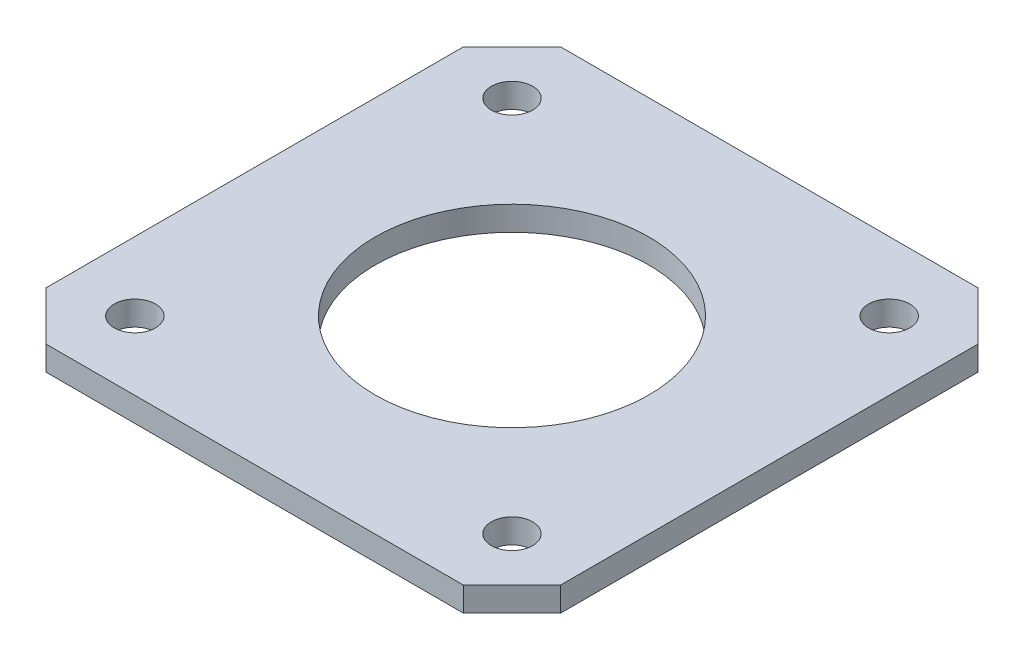
from build123d import *

# Parameters (mm, degrees)
SKETCH1_W            = 42.3
SKETCH1_H            = 42.3
BOSS_EXTRUDE1_DEPTH  = 2
SKETCH2_R            = 11.25
CUT_EXTRUDE1_DEPTH   = 3
M3_CLEARANCE_HOLE1_D = 3.4
CHAMFER1_SIZE        = 4


with BuildPart() as part:
    # Sketch1 → Boss-Extrude1 (new body)
    with BuildSketch(Plane(origin=(0, 0, 0), x_dir=(1, 0, 0), z_dir=(0, 1, 0))):
        Rectangle(SKETCH1_W, SKETCH1_H)
    extrude(amount=BOSS_EXTRUDE1_DEPTH)

    # Sketch2 → Cut-Extrude1 (cut, through all)
    with BuildSketch(Plane(origin=(0, 2, 0), x_dir=(1, 0, 0), z_dir=(0, 1, 0))):
        Circle(SKETCH2_R)
    extrude(amount=-CUT_EXTRUDE1_DEPTH, mode=Mode.SUBTRACT)

    # M3 Clearance Hole1 (through all)
    with Locations(Plane(origin=(0, 2, 0), x_dir=(1, 0, 0), z_dir=(0, 1, 0))):
        with Locations((-15.5, 15.5), (15.5, 15.5), (15.5, -15.5), (-15.5, -15.5)):
            Hole(M3_CLEARANCE_HOLE1_D / 2)

    # Chamfer1
    chamfer1_edges = [part.edges().sort_by_distance(p)[0] for p in [
        (21.15, 1, 21.15),
        (-21.15, 1, 21.15),
        (-21.15, 1, -21.15),
        (21.15, 1, -21.15),
    ]]
    chamfer(chamfer1_edges, length=CHAMFER1_SIZE)


solid = part.part
